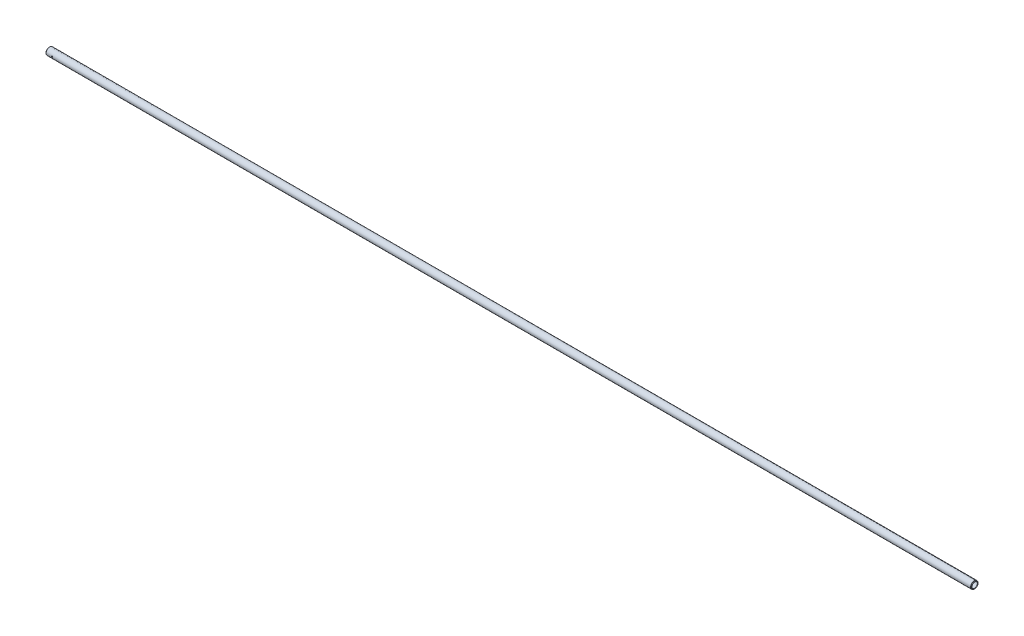
from build123d import *

# Parameters (mm, degrees)
SKETCH2_R          = 0.7874
CUT_EXTRUDE1_DEPTH = 4.5593


with BuildPart() as part:
    # Sketch1 → Revolve1 (revolve)
    with BuildSketch(Plane.XY):
        with BuildLine():
            Line((-0.445028708, 3.689878708), (-0.2794, 3.52425))
            Line((-0.2794, 3.52425), (0, 3.52425))
            Line((0, 3.52425), (0.5588, 4.08305))
            Line((0.5588, 4.08305), (1156.0683, 4.08305))
            Line((1156.0683, 4.08305), (1156.6271, 3.52425))
            Line((1156.6271, 3.52425), (1156.9065, 3.52425))
            Line((1156.9065, 3.52425), (1157.072128708, 3.689878708))
            ThreePointArc((1157.072128708, 3.689878708), (1157.109326147, 3.779681269), (1157.072128708, 3.869483831))
            Line((1157.072128708, 3.869483831), (1156.545981269, 4.395631269))
            ThreePointArc((1156.545981269, 4.395631269), (1156.364693502, 4.516763883), (1156.15085, 4.5593))
            Line((1156.15085, 4.5593), (0.47625, 4.5593))
            ThreePointArc((0.47625, 4.5593), (0.262406498, 4.516763883), (0.081118731, 4.395631269))
            Line((0.081118731, 4.395631269), (-0.445028708, 3.869483831))
            ThreePointArc((-0.445028708, 3.869483831), (-0.482226147, 3.779681269), (-0.445028708, 3.689878708))
        make_face()
    revolve(axis=Axis((1156.6271, 0, 0), (-1, 0, 0)))

    # Sketch2 → Cut-Extrude1 (cut)
    with BuildSketch(Plane.XY):
        with Locations((7.6962, 0)):
            Circle(SKETCH2_R)
    extrude(amount=CUT_EXTRUDE1_DEPTH, mode=Mode.SUBTRACT)


solid = part.part
